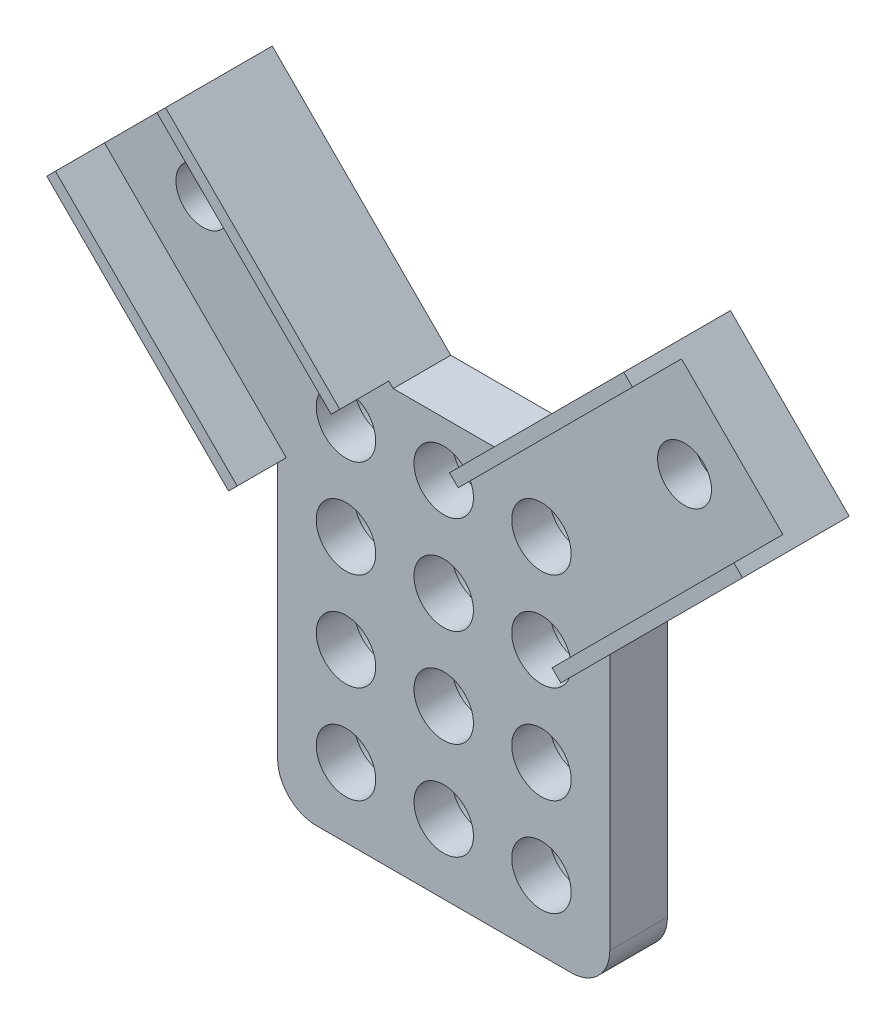
from build123d import *

# Parameters (mm, degrees)
P_IDAT_VYSUNUT_M1_DEPTH  = 4.7
P_IDAT_VYSUNUT_M2_DEPTH  = 4.7
SKICA3_R                 = 2.425
ODEBRAT_VYSUNUT_M1_DEPTH = 14.6
P_IDAT_VYSUNUT_M3_DEPTH  = 4
SKICA5_R                 = 3
ODEBRAT_VYSUNUT_M2_DEPTH = 1.6
SKETCH1_R                = 2.2
CUT_EXTRUDE1_DEPTH       = 3


with BuildPart() as part:
    # Skica1 → Přidat vysunutím1 (new body)
    with BuildSketch(Plane.XY):
        with BuildLine():
            Line((3.15, 0), (23.94, 0))
            ThreePointArc((23.94, 0), (26.167386361, 0.922613639), (27.09, 3.15))
            Line((27.09, 3.15), (27.09, 34))
            Line((27.09, 34), (0, 34))
            Line((0, 34), (0, 3.15))
            ThreePointArc((0, 3.15), (0.922613639, 0.922613639), (3.15, 0))
        make_face()
    extrude(amount=P_IDAT_VYSUNUT_M1_DEPTH)

    # Skica2 → Přidat vysunutím2 (add)
    with BuildSketch(Plane(origin=(0, 0, 0), x_dir=(-1, 0, 0), z_dir=(0, 0, -1))):
        Polygon((-9.71157467, 33.71157467), (-0.024211768, 24.024211768), (14.825030637, 38.873454173), (5.137667735, 48.560817075), align=None)
        Polygon((-41.915030637, 38.873454173), (-27.065788232, 24.024211768), (-17.37842533, 33.71157467), (-32.227667735, 48.560817075), align=None)
    extrude(amount=-P_IDAT_VYSUNUT_M2_DEPTH)

    # Skica3 → Odebrat vysunutím1 (cut)
    with BuildSketch(Plane.XY.offset(4.7)):
        with Locations((5.575, 29.575)):
            Circle(SKICA3_R)
        with Locations((13.545, 29.575)):
            Circle(SKICA3_R)
        with Locations((21.515, 29.575)):
            Circle(SKICA3_R)
        with Locations((5.575, 21.605)):
            Circle(SKICA3_R)
        with Locations((13.545, 21.605)):
            Circle(SKICA3_R)
        with Locations((21.515, 21.605)):
            Circle(SKICA3_R)
        with Locations((21.515, 13.635)):
            Circle(SKICA3_R)
        with Locations((13.545, 13.635)):
            Circle(SKICA3_R)
        with Locations((5.575, 13.635)):
            Circle(SKICA3_R)
        with Locations((5.575, 5.665)):
            Circle(SKICA3_R)
        with Locations((13.545, 5.665)):
            Circle(SKICA3_R)
        with Locations((21.515, 5.665)):
            Circle(SKICA3_R)
    extrude(amount=-ODEBRAT_VYSUNUT_M1_DEPTH, mode=Mode.SUBTRACT)

    # Skica4 → Přidat vysunutím3 (add)
    with BuildSketch(Plane.XY.offset(4.7)):
        Polygon((-5.137667735, 48.560817075), (9.069595949, 34.353553391), (8.362489168, 33.646446609), (-5.844774516, 47.853710294), align=None)
        Polygon((32.227667735, 48.560817075), (18.020404051, 34.353553391), (18.727510832, 33.646446609), (32.934774516, 47.853710294), align=None)
        Polygon((-14.825030637, 38.873454173), (0, 24.048423535), (0.707106781, 24.755530317), (-14.117923856, 39.580560954), align=None)
        Polygon((41.915030637, 38.873454173), (27.09, 24.048423535), (26.382893219, 24.755530317), (41.207923856, 39.580560954), align=None)
    extrude(amount=P_IDAT_VYSUNUT_M3_DEPTH)

    # Skica5 → Odebrat vysunutím2 (cut)
    with BuildSketch(Plane(origin=(0, 0, 0), x_dir=(-1, 0, 0), z_dir=(0, 0, -1))):
        with Locations((-21.515, 29.575)):
            Circle(SKICA5_R)
        with Locations((-13.545, 29.575)):
            Circle(SKICA5_R)
        with Locations((-5.575, 29.575)):
            Circle(SKICA5_R)
        with Locations((-5.575, 21.605)):
            Circle(SKICA5_R)
        with Locations((-13.545, 21.605)):
            Circle(SKICA5_R)
        with Locations((-21.515, 21.605)):
            Circle(SKICA5_R)
        with Locations((-13.545, 5.665)):
            Circle(SKICA5_R)
        with Locations((-21.515, 5.665)):
            Circle(SKICA5_R)
        with Locations((-5.575, 5.665)):
            Circle(SKICA5_R)
        with Locations((-5.575, 13.635)):
            Circle(SKICA5_R)
        with Locations((-13.545, 13.635)):
            Circle(SKICA5_R)
        with Locations((-21.515, 13.635)):
            Circle(SKICA5_R)
    extrude(amount=-ODEBRAT_VYSUNUT_M2_DEPTH, mode=Mode.SUBTRACT)

    # Sketch1 → Cut-Extrude1 (cut)
    with BuildSketch(Plane.XY.offset(4.7)):
        with Locations((-6.09226189, 39.828048327)):
            Circle(SKETCH1_R)
        with Locations((33.18226189, 39.828048327)):
            Circle(SKETCH1_R)
    extrude(amount=-CUT_EXTRUDE1_DEPTH, mode=Mode.SUBTRACT)


solid = part.part
